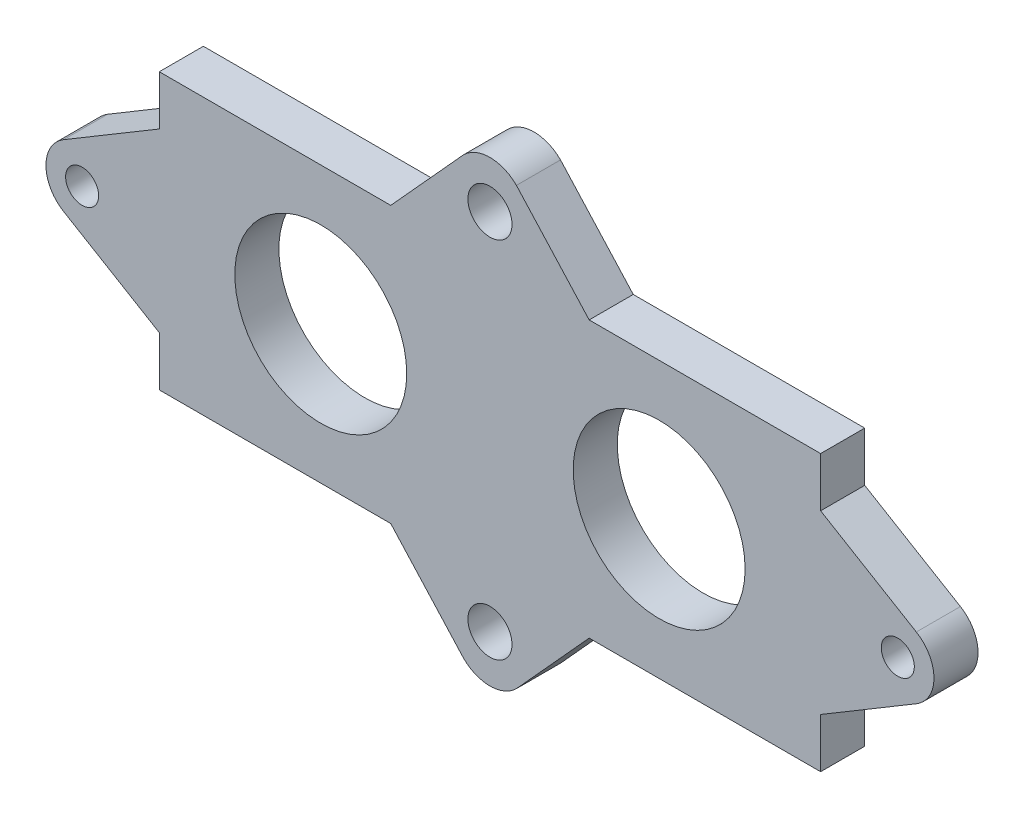
from build123d import *

# Parameters (mm, degrees)
SKETCH1_R           = 7.8
SKETCH1_R_2         = 2
SKETCH1_R_3         = 1.5
BOSS_EXTRUDE1_DEPTH = 4


with BuildPart() as part:
    # Sketch1 → Boss-Extrude1 (new body)
    with BuildSketch(Plane.XY):
        with BuildLine():
            Line((-9, 12.5), (-2.401010284, 19.772380391))
            ThreePointArc((-2.401010284, 19.772380391), (0, 20.766911414), (2.401010284, 19.772380391))
            Line((2.401010284, 19.772380391), (9, 12.5))
            Line((9, 12.5), (30, 12.5))
            Line((30, 12.5), (30, 8))
            Line((30, 8), (38.682501327, 2.820305125))
            ThreePointArc((38.682501327, 2.820305125), (40.284041978, 0), (38.682501327, -2.820305125))
            Line((38.682501327, -2.820305125), (30, -8))
            Line((30, -8), (30, -12.5))
            Line((30, -12.5), (9, -12.5))
            Line((9, -12.5), (2.401010284, -19.772380391))
            ThreePointArc((2.401010284, -19.772380391), (0, -20.766911414), (-2.401010284, -19.772380391))
            Line((-2.401010284, -19.772380391), (-9, -12.5))
            Line((-9, -12.5), (-30, -12.5))
            Line((-30, -12.5), (-30, -8))
            Line((-30, -8), (-38.682501327, -2.820305125))
            ThreePointArc((-38.682501327, -2.820305125), (-40.284041978, 0), (-38.682501327, 2.820305125))
            Line((-38.682501327, 2.820305125), (-30, 8))
            Line((-30, 8), (-30, 12.5))
            Line((-30, 12.5), (-9, 12.5))
        make_face()
        with Locations((-15.35, 0)):
            Circle(SKETCH1_R, mode=Mode.SUBTRACT)
        with Locations((15.35, 0)):
            Circle(SKETCH1_R, mode=Mode.SUBTRACT)
        with Locations((0, 16.5)):
            Circle(SKETCH1_R_2, mode=Mode.SUBTRACT)
        with Locations((0, -16.5)):
            Circle(SKETCH1_R_2, mode=Mode.SUBTRACT)
        with Locations((-37, 0)):
            Circle(SKETCH1_R_3, mode=Mode.SUBTRACT)
        with Locations((37, 0)):
            Circle(SKETCH1_R_3, mode=Mode.SUBTRACT)
    extrude(amount=BOSS_EXTRUDE1_DEPTH)


solid = part.part
